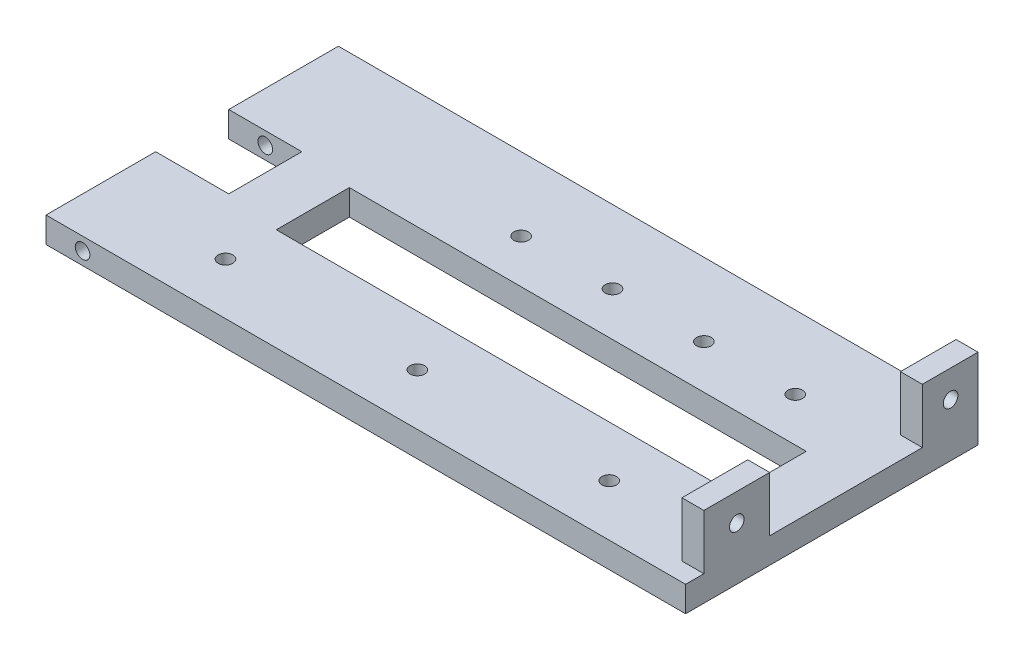
from build123d import *

# Parameters (mm, degrees)
SKETCH1_W               = 175
SKETCH1_H               = 80
BOSS_EXTRUDE1_DEPTH     = 7
SKETCH2_R               = 2
CUT_EXTRUDE1_DEPTH      = 10
SKETCH3_W               = 125
SKETCH3_H               = 20
CUT_EXTRUDE2_DEPTH      = 1
SKETCH7_W               = 6
SKETCH7_H               = 15.226692755
SKETCH7_H_2             = 18
BOSS_EXTRUDE3_DEPTH     = 15
SKETCH8_R               = 2
CUT_EXTRUDE4_DEPTH      = 15
SKETCH9_W               = 20
SKETCH9_H               = 20
CUT_EXTRUDE5_DEPTH      = 15
CUT_EXTRUDE7_DEPTH      = 106.180961029
CUT_EXTRUDE7_DEPTH_BACK = 106.180961029
SKETCH10_R              = 2
SKETCH3_3_W             = 125
SKETCH3_3_H             = 20
CUT_EXTRUDE8_DEPTH      = 10
SKETCH11_R              = 2
CUT_EXTRUDE9_DEPTH      = 10


with BuildPart() as part:
    # Sketch1 → Boss-Extrude1 (new body)
    with BuildSketch(Plane(origin=(0, 0, 0), x_dir=(1, 0, 0), z_dir=(0, 1, 0))):
        with Locations((-2.383449883, -6.993006993)):
            Rectangle(SKETCH1_W, SKETCH1_H)
    extrude(amount=BOSS_EXTRUDE1_DEPTH)

    # Sketch2 → Cut-Extrude1 (cut)
    with BuildSketch(Plane(origin=(0, 7, 0), x_dir=(1, 0, 0), z_dir=(0, 1, 0))):
        with Locations((-54.883449883, -32.893006993)):
            Circle(SKETCH2_R)
        with Locations((-2.383449883, -32.893006993)):
            Circle(SKETCH2_R)
        with Locations((50.116550117, -32.893006993)):
            Circle(SKETCH2_R)
    extrude(amount=-CUT_EXTRUDE1_DEPTH, mode=Mode.SUBTRACT)

    # Sketch3 → Cut-Extrude2 (cut)
    with BuildSketch(Plane(origin=(0, 7, 0), x_dir=(1, 0, 0), z_dir=(0, 1, 0))):
        with Locations((-12.383449883, -8.993006993)):
            Rectangle(SKETCH3_W, SKETCH3_H)
    extrude(amount=-CUT_EXTRUDE2_DEPTH, mode=Mode.SUBTRACT)

    # Sketch7 → Boss-Extrude3 (add)
    with BuildSketch(Plane(origin=(0, 7, 0), x_dir=(1, 0, 0), z_dir=(0, 1, 0))):
        with Locations((-86.883449883, 25.39364663)):
            Rectangle(SKETCH7_W, SKETCH7_H)
        with Locations((-86.883449883, -32.993006993)):
            Rectangle(SKETCH7_W, SKETCH7_H_2)
    extrude(amount=BOSS_EXTRUDE3_DEPTH)

    # Sketch8 → Cut-Extrude4 (cut)
    with BuildSketch(Plane(origin=(-83.883449883, 0, 0), x_dir=(0, 0, -1), z_dir=(1, 0, 0))):
        with Locations((25.506993007, 14.5)):
            Circle(SKETCH8_R)
        with Locations((-32.993006993, 14.5)):
            Circle(SKETCH8_R)
    extrude(amount=-CUT_EXTRUDE4_DEPTH, mode=Mode.SUBTRACT)

    # Sketch9 → Cut-Extrude5 (cut)
    with BuildSketch(Plane.XZ):
        with Locations((75.116550117, 6.993006993)):
            Rectangle(SKETCH9_W, SKETCH9_H)
    extrude(amount=-CUT_EXTRUDE5_DEPTH, mode=Mode.SUBTRACT)

    # Sketch10 → Cut-Extrude7 (cut, two sides: drawn at the far end of the back side and taken through both)
    with BuildSketch(Plane.XY.offset(-3.006993007).offset(-CUT_EXTRUDE7_DEPTH_BACK)):
        with Locations((75.116550117, 3.5)):
            Circle(SKETCH10_R)
    extrude(amount=CUT_EXTRUDE7_DEPTH + CUT_EXTRUDE7_DEPTH_BACK, mode=Mode.SUBTRACT)

    # Sketch3_3 → Cut-Extrude8 (cut)
    with BuildSketch(Plane(origin=(0, 7, 0), x_dir=(1, 0, 0), z_dir=(0, 1, 0))):
        with Locations((-12.383449883, -8.993006993)):
            Rectangle(SKETCH3_3_W, SKETCH3_3_H)
    extrude(amount=-CUT_EXTRUDE8_DEPTH, mode=Mode.SUBTRACT)

    # Sketch11 → Cut-Extrude9 (cut)
    with BuildSketch(Plane(origin=(0, 7, 0), x_dir=(1, 0, 0), z_dir=(0, 1, 0))):
        with Locations((-59.883449883, 13.006993007)):
            Circle(SKETCH11_R)
        with Locations((-34.883449883, 13.006993007)):
            Circle(SKETCH11_R)
        with Locations((-9.883449883, 13.006993007)):
            Circle(SKETCH11_R)
        with Locations((15.116550117, 13.006993007)):
            Circle(SKETCH11_R)
    extrude(amount=-CUT_EXTRUDE9_DEPTH, mode=Mode.SUBTRACT)


with BuildPart() as body_2:
    # Mirror2: mirrored copy
    add(part.part.mirror(Plane(origin=(-89.883449883, 7, -33.006993007), x_dir=(0, 0, 1), z_dir=(1, 0, 0))))


solid = body_2.part
